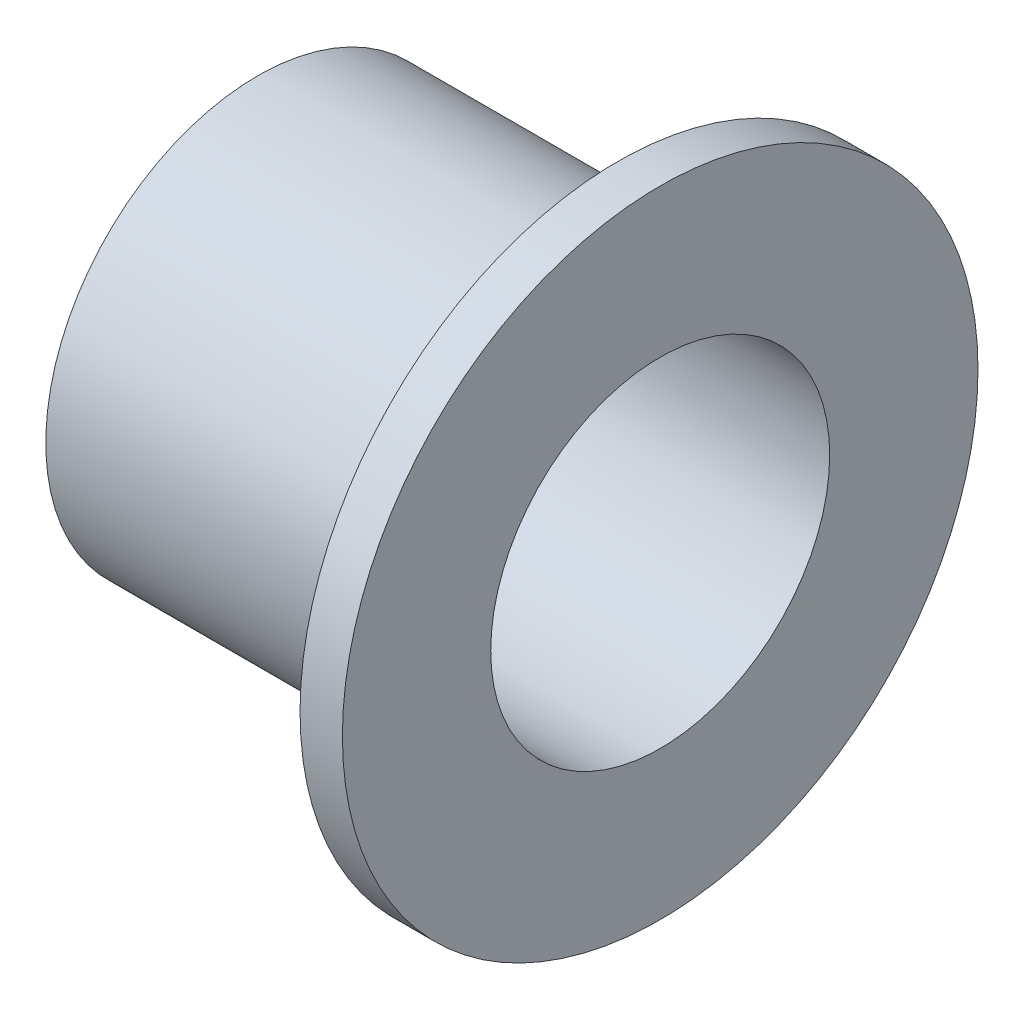
from build123d import *

# Parameters (mm, degrees)
SZKIC1_R                    = 5
SZKIC1_R_2                  = 4
DODANIE_WYCI_GNI_CIE1_DEPTH = 8.5
SZKIC2_R                    = 7.5
SZKIC2_R_2                  = 4
DODANIE_WYCI_GNI_CIE3_DEPTH = 1


with BuildPart() as part:
    # Szkic1 → Dodanie-wyciągnięcie1 (new body)
    with BuildSketch(Plane(origin=(0, 0, 0), x_dir=(0, 0, -1), z_dir=(1, 0, 0))):
        Circle(SZKIC1_R)
        Circle(SZKIC1_R_2, mode=Mode.SUBTRACT)
    extrude(amount=DODANIE_WYCI_GNI_CIE1_DEPTH)

    # Szkic2 → Dodanie-wyciągnięcie3 (add)
    with BuildSketch(Plane(origin=(8.5, 0, 0), x_dir=(0, 0, -1), z_dir=(1, 0, 0))):
        Circle(SZKIC2_R)
        Circle(SZKIC2_R_2, mode=Mode.SUBTRACT)
    extrude(amount=DODANIE_WYCI_GNI_CIE3_DEPTH)


solid = part.part
